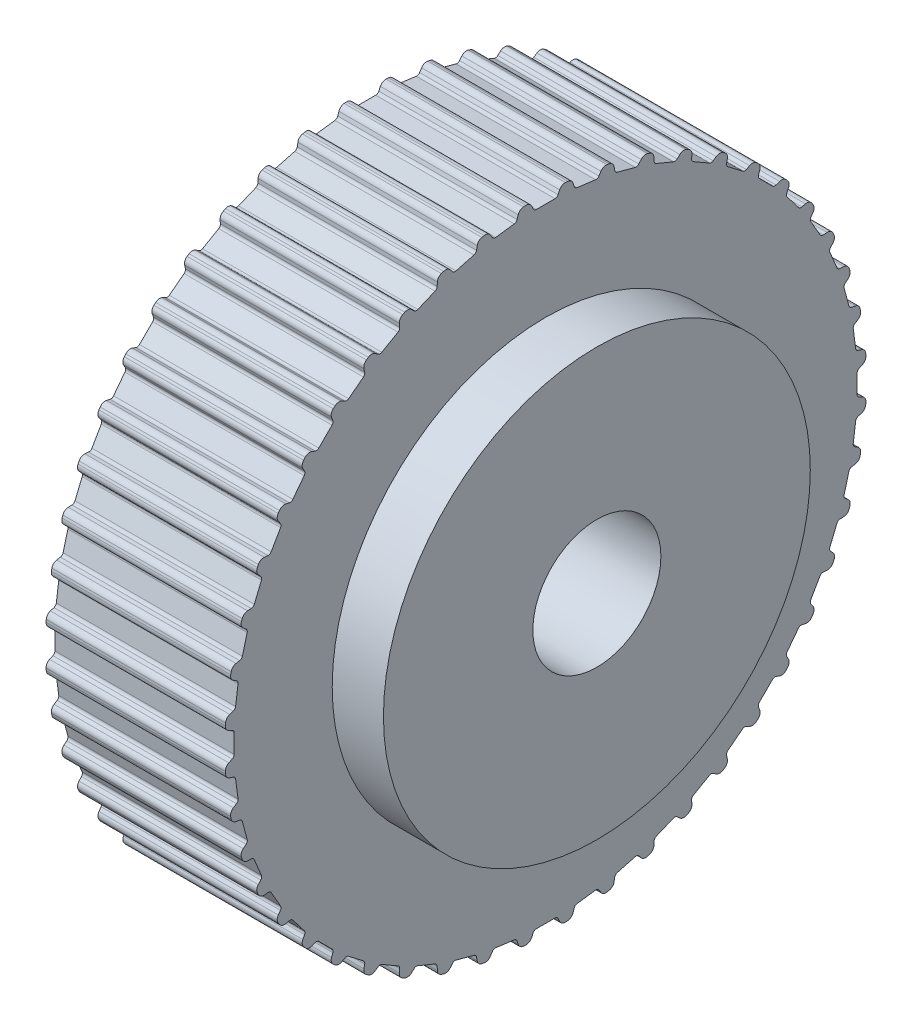
from build123d import *

# Parameters (mm, degrees)
SKETCH1_W                    = 21
SKETCH1_H                    = 37.585
CUT_EXTRUDE1_DEPTH           = 22
CUT_EXTRUDE2_DEPTH           = 22
CUT_EXTRUDE3_DEPTH           = 22
CUT_EXTRUDE4_DEPTH           = 22
CUT_EXTRUDE5_DEPTH           = 22
CUT_EXTRUDE6_DEPTH           = 22
CUT_EXTRUDE7_DEPTH           = 22
CUT_EXTRUDE8_DEPTH           = 22
CUT_EXTRUDE9_DEPTH           = 22
CUT_EXTRUDE10_DEPTH          = 22
CUT_EXTRUDE11_DEPTH          = 22
CUT_EXTRUDE12_DEPTH          = 22
CUT_EXTRUDE13_DEPTH          = 22
CUT_EXTRUDE14_DEPTH          = 22
CUT_EXTRUDE15_DEPTH          = 22
CUT_EXTRUDE16_DEPTH          = 22
CUT_EXTRUDE17_DEPTH          = 22
CUT_EXTRUDE18_DEPTH          = 22
CUT_EXTRUDE19_DEPTH          = 22
CUT_EXTRUDE20_DEPTH          = 22
CUT_EXTRUDE21_DEPTH          = 22
CUT_EXTRUDE22_DEPTH          = 22
CUT_EXTRUDE23_DEPTH          = 22
CUT_EXTRUDE24_DEPTH          = 22
CUT_EXTRUDE25_DEPTH          = 22
CUT_EXTRUDE26_DEPTH          = 22
CUT_EXTRUDE27_DEPTH          = 22
CUT_EXTRUDE28_DEPTH          = 22
CUT_EXTRUDE29_DEPTH          = 22
CUT_EXTRUDE30_DEPTH          = 22
CUT_EXTRUDE31_DEPTH          = 22
CUT_EXTRUDE32_DEPTH          = 22
CUT_EXTRUDE33_DEPTH          = 22
CUT_EXTRUDE34_DEPTH          = 22
CUT_EXTRUDE35_DEPTH          = 22
CUT_EXTRUDE36_DEPTH          = 22
CUT_EXTRUDE37_DEPTH          = 22
CUT_EXTRUDE38_DEPTH          = 22
CUT_EXTRUDE39_DEPTH          = 22
CUT_EXTRUDE40_DEPTH          = 22
CUT_EXTRUDE41_DEPTH          = 22
CUT_EXTRUDE42_DEPTH          = 22
CUT_EXTRUDE43_DEPTH          = 22
CUT_EXTRUDE44_DEPTH          = 22
CUT_EXTRUDE45_DEPTH          = 22
CUT_EXTRUDE46_DEPTH          = 22
CUT_EXTRUDE47_DEPTH          = 22
CUT_EXTRUDE48_DEPTH          = 22
SKETCH50_W                   = 6
SKETCH50_H                   = 25
F_8_0_8_DIAMETER_HOLE1_D     = 8
F_8_0_8_DIAMETER_HOLE1_DEPTH = 27
FILLET1_R                    = 0.4
FILLET2_R                    = 0.7
SKETCH53_R                   = 7.5
CUT_EXTRUDE49_DEPTH          = 28


with BuildPart() as part:
    # Sketch1 → Revolve1 (revolve)
    with BuildSketch(Plane(origin=(0, 0, 0), x_dir=(-1, 0, 0), z_dir=(0, 0, -1))):
        with Locations((-10.5, 18.7925)):
            Rectangle(SKETCH1_W, SKETCH1_H)
    revolve(axis=Axis((21, 0, 0), (-1, 0, 0)))

    # Sketch2 → Cut-Extrude1 (cut, through all)
    with BuildSketch(Plane.ZY):
        with BuildLine():
            Line((3.073809439, 37.459096633), (3.42379756, 36.349076127))
            Line((3.42379756, 36.349076127), (6.100698686, 35.996655408))
            Line((6.100698686, 35.996655408), (6.726055698, 36.978269291))
            ThreePointArc((6.726055698, 36.978269291), (4.905826935, 37.263455115), (3.073809439, 37.459096633))
        make_face()
    extrude(amount=-CUT_EXTRUDE1_DEPTH, mode=Mode.SUBTRACT)

    # Sketch3 → Cut-Extrude2 (cut, through all)
    with BuildSketch(Plane.ZY):
        with BuildLine():
            Line((7.936905821, 36.737416226), (8.139012995, 35.591209483))
            Line((8.139012995, 35.591209483), (10.747012726, 34.892398061))
            Line((10.747012726, 34.892398061), (11.495146045, 35.783988632))
            ThreePointArc((11.495146045, 35.783988632), (9.72771381, 36.304322181), (7.936905821, 36.737416226))
        make_face()
    extrude(amount=-CUT_EXTRUDE2_DEPTH, mode=Mode.SUBTRACT)

    # Sketch4 → Cut-Extrude3 (cut, through all)
    with BuildSketch(Plane.ZY):
        with BuildLine():
            Line((12.664199543, 35.387148443), (12.714967661, 34.224367377))
            Line((12.714967661, 34.224367377), (15.209442399, 33.19112211))
            Line((15.209442399, 33.19112211), (16.067551256, 33.977434006))
            ThreePointArc((16.067551256, 33.977434006), (14.383156805, 34.724012229), (12.664199543, 35.387148443))
        make_face()
    extrude(amount=-CUT_EXTRUDE3_DEPTH, mode=Mode.SUBTRACT)

    # Sketch5 → Cut-Extrude4 (cut, through all)
    with BuildSketch(Plane.ZY):
        with BuildLine():
            Line((17.1748053, 33.431396739), (17.073365705, 32.271936857))
            Line((17.073365705, 32.271936857), (19.411634295, 30.921936857))
            Line((19.411634295, 30.921936857), (20.365036209, 31.589516064))
            ThreePointArc((20.365036209, 31.589516064), (18.7925, 32.549564801), (17.1748053, 33.431396739))
        make_face()
    extrude(amount=-CUT_EXTRUDE4_DEPTH, mode=Mode.SUBTRACT)

    # Sketch6 → Cut-Extrude5 (cut, through all)
    with BuildSketch(Plane.ZY):
        with BuildLine():
            Line((21.391545377, 30.903624567), (21.139633728, 29.76732455))
            Line((21.139633728, 29.76732455), (23.281687747, 28.123668691))
            Line((23.281687747, 28.123668691), (24.314069748, 28.661092745))
            ThreePointArc((24.314069748, 28.661092745), (22.880298309, 29.818185295), (21.391545377, 30.903624567))
        make_face()
    extrude(amount=-CUT_EXTRUDE5_DEPTH, mode=Mode.SUBTRACT)

    # Sketch7 → Cut-Extrude6 (cut, through all)
    with BuildSketch(Plane.ZY):
        with BuildLine():
            Line((25.242270181, 27.847082811), (24.844196757, 26.753385066))
            Line((24.844196757, 26.753385066), (26.753385066, 24.844196757))
            Line((26.753385066, 24.844196757), (27.847082811, 25.242270181))
            ThreePointArc((27.847082811, 25.242270181), (26.576608371, 26.576608371), (25.242270181, 27.847082811))
        make_face()
    extrude(amount=-CUT_EXTRUDE6_DEPTH, mode=Mode.SUBTRACT)

    # Sketch8 → Cut-Extrude7 (cut, through all)
    with BuildSketch(Plane.ZY):
        with BuildLine():
            Line((28.661092745, 24.314069748), (28.123668691, 23.281687747))
            Line((28.123668691, 23.281687747), (29.76732455, 21.139633728))
            Line((29.76732455, 21.139633728), (30.903624567, 21.391545377))
            ThreePointArc((30.903624567, 21.391545377), (29.818185295, 22.880298309), (28.661092745, 24.314069748))
        make_face()
    extrude(amount=-CUT_EXTRUDE7_DEPTH, mode=Mode.SUBTRACT)

    # Sketch9 → Cut-Extrude8 (cut, through all)
    with BuildSketch(Plane.ZY):
        with BuildLine():
            Line((31.589516064, 20.365036209), (30.921936857, 19.411634295))
            Line((30.921936857, 19.411634295), (32.271936857, 17.073365705))
            Line((32.271936857, 17.073365705), (33.431396739, 17.1748053))
            ThreePointArc((33.431396739, 17.1748053), (32.549564801, 18.7925), (31.589516064, 20.365036209))
        make_face()
    extrude(amount=-CUT_EXTRUDE8_DEPTH, mode=Mode.SUBTRACT)

    # Sketch10 → Cut-Extrude9 (cut, through all)
    with BuildSketch(Plane.ZY):
        with BuildLine():
            Line((33.977434006, 16.067551256), (33.19112211, 15.209442399))
            Line((33.19112211, 15.209442399), (34.224367377, 12.714967661))
            Line((34.224367377, 12.714967661), (35.387148443, 12.664199543))
            ThreePointArc((35.387148443, 12.664199543), (34.724012229, 14.383156805), (33.977434006, 16.067551256))
        make_face()
    extrude(amount=-CUT_EXTRUDE9_DEPTH, mode=Mode.SUBTRACT)

    # Sketch11 → Cut-Extrude10 (cut, through all)
    with BuildSketch(Plane.ZY):
        with BuildLine():
            Line((35.783988632, 11.495146045), (34.892398061, 10.747012726))
            Line((34.892398061, 10.747012726), (35.591209483, 8.139012995))
            Line((35.591209483, 8.139012995), (36.737416226, 7.936905821))
            ThreePointArc((36.737416226, 7.936905821), (36.304322181, 9.72771381), (35.783988632, 11.495146045))
        make_face()
    extrude(amount=-CUT_EXTRUDE10_DEPTH, mode=Mode.SUBTRACT)

    # Sketch12 → Cut-Extrude11 (cut, through all)
    with BuildSketch(Plane.ZY):
        with BuildLine():
            Line((36.978269291, 6.726055698), (35.996655408, 6.100698686))
            Line((35.996655408, 6.100698686), (36.349076127, 3.42379756))
            Line((36.349076127, 3.42379756), (37.459096633, 3.073809439))
            ThreePointArc((37.459096633, 3.073809439), (37.263455115, 4.905826935), (36.978269291, 6.726055698))
        make_face()
    extrude(amount=-CUT_EXTRUDE11_DEPTH, mode=Mode.SUBTRACT)

    # Sketch13 → Cut-Extrude12 (cut, through all)
    with BuildSketch(Plane.ZY):
        with BuildLine():
            Line((37.53984151, 1.841880674), (36.485, 1.35))
            Line((36.485, 1.35), (36.485, -1.35))
            Line((36.485, -1.35), (37.53984151, -1.841880674))
            ThreePointArc((37.53984151, -1.841880674), (37.585, 0), (37.53984151, 1.841880674))
        make_face()
    extrude(amount=-CUT_EXTRUDE12_DEPTH, mode=Mode.SUBTRACT)

    # Sketch14 → Cut-Extrude13 (cut, through all)
    with BuildSketch(Plane.ZY):
        with BuildLine():
            Line((37.459096633, -3.073809439), (36.349076127, -3.42379756))
            Line((36.349076127, -3.42379756), (35.996655408, -6.100698686))
            Line((35.996655408, -6.100698686), (36.978269291, -6.726055698))
            ThreePointArc((36.978269291, -6.726055698), (37.263455115, -4.905826935), (37.459096633, -3.073809439))
        make_face()
    extrude(amount=-CUT_EXTRUDE13_DEPTH, mode=Mode.SUBTRACT)

    # Sketch15 → Cut-Extrude14 (cut, through all)
    with BuildSketch(Plane.ZY):
        with BuildLine():
            Line((36.737416226, -7.936905821), (35.591209483, -8.139012995))
            Line((35.591209483, -8.139012995), (34.892398061, -10.747012726))
            Line((34.892398061, -10.747012726), (35.783988632, -11.495146045))
            ThreePointArc((35.783988632, -11.495146045), (36.304322181, -9.72771381), (36.737416226, -7.936905821))
        make_face()
    extrude(amount=-CUT_EXTRUDE14_DEPTH, mode=Mode.SUBTRACT)

    # Sketch16 → Cut-Extrude15 (cut, through all)
    with BuildSketch(Plane.ZY):
        with BuildLine():
            Line((35.387148443, -12.664199543), (34.224367377, -12.714967661))
            Line((34.224367377, -12.714967661), (33.19112211, -15.209442399))
            Line((33.19112211, -15.209442399), (33.977434006, -16.067551256))
            ThreePointArc((33.977434006, -16.067551256), (34.724012229, -14.383156805), (35.387148443, -12.664199543))
        make_face()
    extrude(amount=-CUT_EXTRUDE15_DEPTH, mode=Mode.SUBTRACT)

    # Sketch17 → Cut-Extrude16 (cut, through all)
    with BuildSketch(Plane.ZY):
        with BuildLine():
            Line((33.431396739, -17.1748053), (32.271936857, -17.073365705))
            Line((32.271936857, -17.073365705), (30.921936857, -19.411634295))
            Line((30.921936857, -19.411634295), (31.589516064, -20.365036209))
            ThreePointArc((31.589516064, -20.365036209), (32.549564801, -18.7925), (33.431396739, -17.1748053))
        make_face()
    extrude(amount=-CUT_EXTRUDE16_DEPTH, mode=Mode.SUBTRACT)

    # Sketch18 → Cut-Extrude17 (cut, through all)
    with BuildSketch(Plane.ZY):
        with BuildLine():
            Line((30.903624567, -21.391545377), (29.76732455, -21.139633728))
            Line((29.76732455, -21.139633728), (28.123668691, -23.281687747))
            Line((28.123668691, -23.281687747), (28.661092745, -24.314069748))
            ThreePointArc((28.661092745, -24.314069748), (29.818185295, -22.880298309), (30.903624567, -21.391545377))
        make_face()
    extrude(amount=-CUT_EXTRUDE17_DEPTH, mode=Mode.SUBTRACT)

    # Sketch19 → Cut-Extrude18 (cut, through all)
    with BuildSketch(Plane.ZY):
        with BuildLine():
            Line((27.847082811, -25.242270181), (26.753385066, -24.844196757))
            Line((26.753385066, -24.844196757), (24.844196757, -26.753385066))
            Line((24.844196757, -26.753385066), (25.242270181, -27.847082811))
            ThreePointArc((25.242270181, -27.847082811), (26.576608371, -26.576608371), (27.847082811, -25.242270181))
        make_face()
    extrude(amount=-CUT_EXTRUDE18_DEPTH, mode=Mode.SUBTRACT)

    # Sketch20 → Cut-Extrude19 (cut, through all)
    with BuildSketch(Plane.ZY):
        with BuildLine():
            Line((24.314069748, -28.661092745), (23.281687747, -28.123668691))
            Line((23.281687747, -28.123668691), (21.139633728, -29.76732455))
            Line((21.139633728, -29.76732455), (21.391545377, -30.903624567))
            ThreePointArc((21.391545377, -30.903624567), (22.880298309, -29.818185295), (24.314069748, -28.661092745))
        make_face()
    extrude(amount=-CUT_EXTRUDE19_DEPTH, mode=Mode.SUBTRACT)

    # Sketch21 → Cut-Extrude20 (cut, through all)
    with BuildSketch(Plane.ZY):
        with BuildLine():
            Line((20.365036209, -31.589516064), (19.411634295, -30.921936857))
            Line((19.411634295, -30.921936857), (17.073365705, -32.271936857))
            Line((17.073365705, -32.271936857), (17.1748053, -33.431396739))
            ThreePointArc((17.1748053, -33.431396739), (18.7925, -32.549564801), (20.365036209, -31.589516064))
        make_face()
    extrude(amount=-CUT_EXTRUDE20_DEPTH, mode=Mode.SUBTRACT)

    # Sketch22 → Cut-Extrude21 (cut, through all)
    with BuildSketch(Plane.ZY):
        with BuildLine():
            Line((16.067551256, -33.977434006), (15.209442399, -33.19112211))
            Line((15.209442399, -33.19112211), (12.714967661, -34.224367377))
            Line((12.714967661, -34.224367377), (12.664199543, -35.387148443))
            ThreePointArc((12.664199543, -35.387148443), (14.383156805, -34.724012229), (16.067551256, -33.977434006))
        make_face()
    extrude(amount=-CUT_EXTRUDE21_DEPTH, mode=Mode.SUBTRACT)

    # Sketch23 → Cut-Extrude22 (cut, through all)
    with BuildSketch(Plane.ZY):
        with BuildLine():
            Line((11.495146045, -35.783988632), (10.747012726, -34.892398061))
            Line((10.747012726, -34.892398061), (8.139012995, -35.591209483))
            Line((8.139012995, -35.591209483), (7.936905821, -36.737416226))
            ThreePointArc((7.936905821, -36.737416226), (9.72771381, -36.304322181), (11.495146045, -35.783988632))
        make_face()
    extrude(amount=-CUT_EXTRUDE22_DEPTH, mode=Mode.SUBTRACT)

    # Sketch24 → Cut-Extrude23 (cut, through all)
    with BuildSketch(Plane.ZY):
        with BuildLine():
            Line((6.726055698, -36.978269291), (6.100698686, -35.996655408))
            Line((6.100698686, -35.996655408), (3.42379756, -36.349076127))
            Line((3.42379756, -36.349076127), (3.073809439, -37.459096633))
            ThreePointArc((3.073809439, -37.459096633), (4.905826935, -37.263455115), (6.726055698, -36.978269291))
        make_face()
    extrude(amount=-CUT_EXTRUDE23_DEPTH, mode=Mode.SUBTRACT)

    # Sketch25 → Cut-Extrude24 (cut, through all)
    with BuildSketch(Plane.ZY):
        with BuildLine():
            Line((1.841880674, -37.53984151), (1.35, -36.485))
            Line((1.35, -36.485), (-1.35, -36.485))
            Line((-1.35, -36.485), (-1.841880674, -37.53984151))
            ThreePointArc((-1.841880674, -37.53984151), (0, -37.585), (1.841880674, -37.53984151))
        make_face()
    extrude(amount=-CUT_EXTRUDE24_DEPTH, mode=Mode.SUBTRACT)

    # Sketch26 → Cut-Extrude25 (cut, through all)
    with BuildSketch(Plane.ZY):
        with BuildLine():
            Line((-3.073809439, -37.459096633), (-3.42379756, -36.349076127))
            Line((-3.42379756, -36.349076127), (-6.100698686, -35.996655408))
            Line((-6.100698686, -35.996655408), (-6.726055698, -36.978269291))
            ThreePointArc((-6.726055698, -36.978269291), (-4.905826935, -37.263455115), (-3.073809439, -37.459096633))
        make_face()
    extrude(amount=-CUT_EXTRUDE25_DEPTH, mode=Mode.SUBTRACT)

    # Sketch27 → Cut-Extrude26 (cut, through all)
    with BuildSketch(Plane.ZY):
        with BuildLine():
            Line((-7.936905821, -36.737416226), (-8.139012995, -35.591209483))
            Line((-8.139012995, -35.591209483), (-10.747012726, -34.892398061))
            Line((-10.747012726, -34.892398061), (-11.495146045, -35.783988632))
            ThreePointArc((-11.495146045, -35.783988632), (-9.72771381, -36.304322181), (-7.936905821, -36.737416226))
        make_face()
    extrude(amount=-CUT_EXTRUDE26_DEPTH, mode=Mode.SUBTRACT)

    # Sketch28 → Cut-Extrude27 (cut, through all)
    with BuildSketch(Plane.ZY):
        with BuildLine():
            Line((-12.664199543, -35.387148443), (-12.714967661, -34.224367377))
            Line((-12.714967661, -34.224367377), (-15.209442399, -33.19112211))
            Line((-15.209442399, -33.19112211), (-16.067551256, -33.977434006))
            ThreePointArc((-16.067551256, -33.977434006), (-14.383156805, -34.724012229), (-12.664199543, -35.387148443))
        make_face()
    extrude(amount=-CUT_EXTRUDE27_DEPTH, mode=Mode.SUBTRACT)

    # Sketch29 → Cut-Extrude28 (cut, through all)
    with BuildSketch(Plane.ZY):
        with BuildLine():
            Line((-17.1748053, -33.431396739), (-17.073365705, -32.271936857))
            Line((-17.073365705, -32.271936857), (-19.411634295, -30.921936857))
            Line((-19.411634295, -30.921936857), (-20.365036209, -31.589516064))
            ThreePointArc((-20.365036209, -31.589516064), (-18.7925, -32.549564801), (-17.1748053, -33.431396739))
        make_face()
    extrude(amount=-CUT_EXTRUDE28_DEPTH, mode=Mode.SUBTRACT)

    # Sketch30 → Cut-Extrude29 (cut, through all)
    with BuildSketch(Plane.ZY):
        with BuildLine():
            Line((-21.391545377, -30.903624567), (-21.139633728, -29.76732455))
            Line((-21.139633728, -29.76732455), (-23.281687747, -28.123668691))
            Line((-23.281687747, -28.123668691), (-24.314069748, -28.661092745))
            ThreePointArc((-24.314069748, -28.661092745), (-22.880298309, -29.818185295), (-21.391545377, -30.903624567))
        make_face()
    extrude(amount=-CUT_EXTRUDE29_DEPTH, mode=Mode.SUBTRACT)

    # Sketch31 → Cut-Extrude30 (cut, through all)
    with BuildSketch(Plane.ZY):
        with BuildLine():
            Line((-25.242270181, -27.847082811), (-24.844196757, -26.753385066))
            Line((-24.844196757, -26.753385066), (-26.753385066, -24.844196757))
            Line((-26.753385066, -24.844196757), (-27.847082811, -25.242270181))
            ThreePointArc((-27.847082811, -25.242270181), (-26.576608371, -26.576608371), (-25.242270181, -27.847082811))
        make_face()
    extrude(amount=-CUT_EXTRUDE30_DEPTH, mode=Mode.SUBTRACT)

    # Sketch32 → Cut-Extrude31 (cut, through all)
    with BuildSketch(Plane.ZY):
        with BuildLine():
            Line((-28.661092745, -24.314069748), (-28.123668691, -23.281687747))
            Line((-28.123668691, -23.281687747), (-29.76732455, -21.139633728))
            Line((-29.76732455, -21.139633728), (-30.903624567, -21.391545377))
            ThreePointArc((-30.903624567, -21.391545377), (-29.818185295, -22.880298309), (-28.661092745, -24.314069748))
        make_face()
    extrude(amount=-CUT_EXTRUDE31_DEPTH, mode=Mode.SUBTRACT)

    # Sketch33 → Cut-Extrude32 (cut, through all)
    with BuildSketch(Plane.ZY):
        with BuildLine():
            Line((-31.589516064, -20.365036209), (-30.921936857, -19.411634295))
            Line((-30.921936857, -19.411634295), (-32.271936857, -17.073365705))
            Line((-32.271936857, -17.073365705), (-33.431396739, -17.1748053))
            ThreePointArc((-33.431396739, -17.1748053), (-32.549564801, -18.7925), (-31.589516064, -20.365036209))
        make_face()
    extrude(amount=-CUT_EXTRUDE32_DEPTH, mode=Mode.SUBTRACT)

    # Sketch34 → Cut-Extrude33 (cut, through all)
    with BuildSketch(Plane.ZY):
        with BuildLine():
            Line((-33.977434006, -16.067551256), (-33.19112211, -15.209442399))
            Line((-33.19112211, -15.209442399), (-34.224367377, -12.714967661))
            Line((-34.224367377, -12.714967661), (-35.387148443, -12.664199543))
            ThreePointArc((-35.387148443, -12.664199543), (-34.724012229, -14.383156805), (-33.977434006, -16.067551256))
        make_face()
    extrude(amount=-CUT_EXTRUDE33_DEPTH, mode=Mode.SUBTRACT)

    # Sketch35 → Cut-Extrude34 (cut, through all)
    with BuildSketch(Plane.ZY):
        with BuildLine():
            Line((-35.783988632, -11.495146045), (-34.892398061, -10.747012726))
            Line((-34.892398061, -10.747012726), (-35.591209483, -8.139012995))
            Line((-35.591209483, -8.139012995), (-36.737416226, -7.936905821))
            ThreePointArc((-36.737416226, -7.936905821), (-36.304322181, -9.72771381), (-35.783988632, -11.495146045))
        make_face()
    extrude(amount=-CUT_EXTRUDE34_DEPTH, mode=Mode.SUBTRACT)

    # Sketch36 → Cut-Extrude35 (cut, through all)
    with BuildSketch(Plane.ZY):
        with BuildLine():
            Line((-36.978269291, -6.726055698), (-35.996655408, -6.100698686))
            Line((-35.996655408, -6.100698686), (-36.349076127, -3.42379756))
            Line((-36.349076127, -3.42379756), (-37.459096633, -3.073809439))
            ThreePointArc((-37.459096633, -3.073809439), (-37.263455115, -4.905826935), (-36.978269291, -6.726055698))
        make_face()
    extrude(amount=-CUT_EXTRUDE35_DEPTH, mode=Mode.SUBTRACT)

    # Sketch37 → Cut-Extrude36 (cut, through all)
    with BuildSketch(Plane.ZY):
        with BuildLine():
            Line((-37.53984151, -1.841880674), (-36.485, -1.35))
            Line((-36.485, -1.35), (-36.485, 1.35))
            Line((-36.485, 1.35), (-37.53984151, 1.841880674))
            ThreePointArc((-37.53984151, 1.841880674), (-37.585, 0), (-37.53984151, -1.841880674))
        make_face()
    extrude(amount=-CUT_EXTRUDE36_DEPTH, mode=Mode.SUBTRACT)

    # Sketch38 → Cut-Extrude37 (cut, through all)
    with BuildSketch(Plane.ZY):
        with BuildLine():
            Line((-37.459096633, 3.073809439), (-36.349076127, 3.42379756))
            Line((-36.349076127, 3.42379756), (-35.996655408, 6.100698686))
            Line((-35.996655408, 6.100698686), (-36.978269291, 6.726055698))
            ThreePointArc((-36.978269291, 6.726055698), (-37.263455115, 4.905826935), (-37.459096633, 3.073809439))
        make_face()
    extrude(amount=-CUT_EXTRUDE37_DEPTH, mode=Mode.SUBTRACT)

    # Sketch39 → Cut-Extrude38 (cut, through all)
    with BuildSketch(Plane.ZY):
        with BuildLine():
            Line((-36.737416226, 7.936905821), (-35.591209483, 8.139012995))
            Line((-35.591209483, 8.139012995), (-34.892398061, 10.747012726))
            Line((-34.892398061, 10.747012726), (-35.783988632, 11.495146045))
            ThreePointArc((-35.783988632, 11.495146045), (-36.304322181, 9.72771381), (-36.737416226, 7.936905821))
        make_face()
    extrude(amount=-CUT_EXTRUDE38_DEPTH, mode=Mode.SUBTRACT)

    # Sketch40 → Cut-Extrude39 (cut, through all)
    with BuildSketch(Plane.ZY):
        with BuildLine():
            Line((-35.387148443, 12.664199543), (-34.224367377, 12.714967661))
            Line((-34.224367377, 12.714967661), (-33.19112211, 15.209442399))
            Line((-33.19112211, 15.209442399), (-33.977434006, 16.067551256))
            ThreePointArc((-33.977434006, 16.067551256), (-34.724012229, 14.383156805), (-35.387148443, 12.664199543))
        make_face()
    extrude(amount=-CUT_EXTRUDE39_DEPTH, mode=Mode.SUBTRACT)

    # Sketch41 → Cut-Extrude40 (cut, through all)
    with BuildSketch(Plane.ZY):
        with BuildLine():
            Line((-33.431396739, 17.1748053), (-32.271936857, 17.073365705))
            Line((-32.271936857, 17.073365705), (-30.921936857, 19.411634295))
            Line((-30.921936857, 19.411634295), (-31.589516064, 20.365036209))
            ThreePointArc((-31.589516064, 20.365036209), (-32.549564801, 18.7925), (-33.431396739, 17.1748053))
        make_face()
    extrude(amount=-CUT_EXTRUDE40_DEPTH, mode=Mode.SUBTRACT)

    # Sketch42 → Cut-Extrude41 (cut, through all)
    with BuildSketch(Plane.ZY):
        with BuildLine():
            Line((-30.903624567, 21.391545377), (-29.76732455, 21.139633728))
            Line((-29.76732455, 21.139633728), (-28.123668691, 23.281687747))
            Line((-28.123668691, 23.281687747), (-28.661092745, 24.314069748))
            ThreePointArc((-28.661092745, 24.314069748), (-29.818185295, 22.880298309), (-30.903624567, 21.391545377))
        make_face()
    extrude(amount=-CUT_EXTRUDE41_DEPTH, mode=Mode.SUBTRACT)

    # Sketch43 → Cut-Extrude42 (cut, through all)
    with BuildSketch(Plane.ZY):
        with BuildLine():
            Line((-27.847082811, 25.242270181), (-26.753385066, 24.844196757))
            Line((-26.753385066, 24.844196757), (-24.844196757, 26.753385066))
            Line((-24.844196757, 26.753385066), (-25.242270181, 27.847082811))
            ThreePointArc((-25.242270181, 27.847082811), (-26.576608371, 26.576608371), (-27.847082811, 25.242270181))
        make_face()
    extrude(amount=-CUT_EXTRUDE42_DEPTH, mode=Mode.SUBTRACT)

    # Sketch44 → Cut-Extrude43 (cut, through all)
    with BuildSketch(Plane.ZY):
        with BuildLine():
            Line((-24.314069748, 28.661092745), (-23.281687747, 28.123668691))
            Line((-23.281687747, 28.123668691), (-21.139633728, 29.76732455))
            Line((-21.139633728, 29.76732455), (-21.391545377, 30.903624567))
            ThreePointArc((-21.391545377, 30.903624567), (-22.880298309, 29.818185295), (-24.314069748, 28.661092745))
        make_face()
    extrude(amount=-CUT_EXTRUDE43_DEPTH, mode=Mode.SUBTRACT)

    # Sketch45 → Cut-Extrude44 (cut, through all)
    with BuildSketch(Plane.ZY):
        with BuildLine():
            Line((-20.365036209, 31.589516064), (-19.411634295, 30.921936857))
            Line((-19.411634295, 30.921936857), (-17.073365705, 32.271936857))
            Line((-17.073365705, 32.271936857), (-17.1748053, 33.431396739))
            ThreePointArc((-17.1748053, 33.431396739), (-18.7925, 32.549564801), (-20.365036209, 31.589516064))
        make_face()
    extrude(amount=-CUT_EXTRUDE44_DEPTH, mode=Mode.SUBTRACT)

    # Sketch46 → Cut-Extrude45 (cut, through all)
    with BuildSketch(Plane.ZY):
        with BuildLine():
            Line((-16.067551256, 33.977434006), (-15.209442399, 33.19112211))
            Line((-15.209442399, 33.19112211), (-12.714967661, 34.224367377))
            Line((-12.714967661, 34.224367377), (-12.664199543, 35.387148443))
            ThreePointArc((-12.664199543, 35.387148443), (-14.383156805, 34.724012229), (-16.067551256, 33.977434006))
        make_face()
    extrude(amount=-CUT_EXTRUDE45_DEPTH, mode=Mode.SUBTRACT)

    # Sketch47 → Cut-Extrude46 (cut, through all)
    with BuildSketch(Plane.ZY):
        with BuildLine():
            Line((-11.495146045, 35.783988632), (-10.747012726, 34.892398061))
            Line((-10.747012726, 34.892398061), (-8.139012995, 35.591209483))
            Line((-8.139012995, 35.591209483), (-7.936905821, 36.737416226))
            ThreePointArc((-7.936905821, 36.737416226), (-9.72771381, 36.304322181), (-11.495146045, 35.783988632))
        make_face()
    extrude(amount=-CUT_EXTRUDE46_DEPTH, mode=Mode.SUBTRACT)

    # Sketch48 → Cut-Extrude47 (cut, through all)
    with BuildSketch(Plane.ZY):
        with BuildLine():
            Line((-6.726055698, 36.978269291), (-6.100698686, 35.996655408))
            Line((-6.100698686, 35.996655408), (-3.42379756, 36.349076127))
            Line((-3.42379756, 36.349076127), (-3.073809439, 37.459096633))
            ThreePointArc((-3.073809439, 37.459096633), (-4.905826935, 37.263455115), (-6.726055698, 36.978269291))
        make_face()
    extrude(amount=-CUT_EXTRUDE47_DEPTH, mode=Mode.SUBTRACT)

    # Sketch49 → Cut-Extrude48 (cut, through all)
    with BuildSketch(Plane.ZY):
        with BuildLine():
            Line((-1.841880674, 37.53984151), (-1.35, 36.485))
            Line((-1.35, 36.485), (1.35, 36.485))
            Line((1.35, 36.485), (1.841880674, 37.53984151))
            ThreePointArc((1.841880674, 37.53984151), (0, 37.585), (-1.841880674, 37.53984151))
        make_face()
    extrude(amount=-CUT_EXTRUDE48_DEPTH, mode=Mode.SUBTRACT)

    # Sketch50 → Revolve2 (revolve)
    with BuildSketch(Plane(origin=(0, 0, 0), x_dir=(-1, 0, 0), z_dir=(0, 0, -1))):
        with Locations((-24, 12.5)):
            Rectangle(SKETCH50_W, SKETCH50_H)
    revolve(axis=Axis((27, 0, 0), (-1, 0, 0)))

    # Ø8.0 (8) Diameter Hole1
    with Locations(Plane(origin=(27, 0, 0), x_dir=(0, 0, -1), z_dir=(1, 0, 0))):
        with Locations((0, 0)):
            Hole(F_8_0_8_DIAMETER_HOLE1_D / 2, depth=F_8_0_8_DIAMETER_HOLE1_DEPTH)

    # Fillet1
    fillet1_edges = [part.edges().sort_by_distance(p)[0] for p in [
        (10.5, 21.139633728, 29.76732455),
        (10.5, 23.281687747, 28.123668691),
        (10.5, 17.073365705, 32.271936857),
        (10.5, 19.411634295, 30.921936857),
        (10.5, 35.996655408, 6.100698686),
        (10.5, 12.714967661, 34.224367377),
        (10.5, 15.209442399, 33.19112211),
        (10.5, 36.349076127, 3.42379756),
        (10.5, 8.139012995, 35.591209483),
        (10.5, 10.747012726, 34.892398061),
        (10.5, 3.42379756, 36.349076127),
        (10.5, 6.100698686, 35.996655408),
        (10.5, -1.35, 36.485),
        (10.5, 1.35, 36.485),
        (10.5, -6.100698686, 35.996655408),
        (10.5, -3.42379756, 36.349076127),
        (10.5, -10.747012726, 34.892398061),
        (10.5, -8.139012995, 35.591209483),
        (10.5, -15.209442399, 33.19112211),
        (10.5, -12.714967661, 34.224367377),
        (10.5, -19.411634295, 30.921936857),
        (10.5, -17.073365705, 32.271936857),
        (10.5, -23.281687747, 28.123668691),
        (10.5, -21.139633728, 29.76732455),
        (10.5, 34.892398061, 10.747012726),
        (10.5, -26.753385066, 24.844196757),
        (10.5, -24.844196757, 26.753385066),
        (10.5, 35.591209483, 8.139012995),
        (10.5, -29.76732455, 21.139633728),
        (10.5, -28.123668691, 23.281687747),
        (10.5, -32.271936857, 17.073365705),
        (10.5, -30.921936857, 19.411634295),
        (10.5, -34.224367377, 12.714967661),
        (10.5, -33.19112211, 15.209442399),
        (10.5, -35.591209483, 8.139012995),
        (10.5, -34.892398061, 10.747012726),
        (10.5, -36.349076127, 3.42379756),
        (10.5, -35.996655408, 6.100698686),
        (10.5, -36.485, -1.35),
        (10.5, -36.485, 1.35),
        (10.5, -35.996655408, -6.100698686),
        (10.5, -36.349076127, -3.42379756),
        (10.5, -34.892398061, -10.747012726),
        (10.5, -35.591209483, -8.139012995),
        (10.5, -33.19112211, -15.209442399),
        (10.5, -34.224367377, -12.714967661),
        (10.5, -30.921936857, -19.411634295),
        (10.5, -32.271936857, -17.073365705),
        (10.5, 33.19112211, 15.209442399),
        (10.5, 34.224367377, 12.714967661),
        (10.5, -28.123668691, -23.281687747),
        (10.5, -29.76732455, -21.139633728),
        (10.5, -24.844196757, -26.753385066),
        (10.5, -26.753385066, -24.844196757),
        (10.5, -21.139633728, -29.76732455),
        (10.5, -23.281687747, -28.123668691),
        (10.5, -17.073365705, -32.271936857),
        (10.5, -19.411634295, -30.921936857),
        (10.5, -12.714967661, -34.224367377),
        (10.5, -15.209442399, -33.19112211),
        (10.5, -8.139012995, -35.591209483),
        (10.5, -10.747012726, -34.892398061),
        (10.5, -3.42379756, -36.349076127),
        (10.5, -6.100698686, -35.996655408),
        (10.5, 1.35, -36.485),
        (10.5, -1.35, -36.485),
        (10.5, 6.100698686, -35.996655408),
        (10.5, 3.42379756, -36.349076127),
        (10.5, 10.747012726, -34.892398061),
        (10.5, 8.139012995, -35.591209483),
        (10.5, 15.209442399, -33.19112211),
        (10.5, 12.714967661, -34.224367377),
        (10.5, 30.921936857, 19.411634295),
        (10.5, 32.271936857, 17.073365705),
        (10.5, 19.411634295, -30.921936857),
        (10.5, 17.073365705, -32.271936857),
        (10.5, 23.281687747, -28.123668691),
        (10.5, 21.139633728, -29.76732455),
        (10.5, 26.753385066, -24.844196757),
        (10.5, 24.844196757, -26.753385066),
        (10.5, 29.76732455, -21.139633728),
        (10.5, 28.123668691, -23.281687747),
        (10.5, 32.271936857, -17.073365705),
        (10.5, 30.921936857, -19.411634295),
        (10.5, 34.224367377, -12.714967661),
        (10.5, 33.19112211, -15.209442399),
        (10.5, 35.591209483, -8.139012995),
        (10.5, 34.892398061, -10.747012726),
        (10.5, 36.349076127, -3.42379756),
        (10.5, 35.996655408, -6.100698686),
        (10.5, 36.485, 1.35),
        (10.5, 36.485, -1.35),
        (10.5, 28.123668691, 23.281687747),
        (10.5, 29.76732455, 21.139633728),
        (10.5, 24.844196757, 26.753385066),
        (10.5, 26.753385066, 24.844196757),
    ]]
    fillet(fillet1_edges, radius=FILLET1_R)

    # Fillet2
    fillet2_edges = [part.edges().sort_by_distance(p)[0] for p in [
        (10.5, 24.314069748, 28.661092745),
        (10.5, 21.391545377, 30.903624567),
        (10.5, 20.365036209, 31.589516064),
        (10.5, 17.1748053, 33.431396739),
        (10.5, 37.459096633, 3.073809439),
        (10.5, 36.978269291, 6.726055698),
        (10.5, 16.067551256, 33.977434006),
        (10.5, 12.664199543, 35.387148443),
        (10.5, 11.495146045, 35.783988632),
        (10.5, 7.936905821, 36.737416226),
        (10.5, 6.726055698, 36.978269291),
        (10.5, 3.073809439, 37.459096633),
        (10.5, 1.841880674, 37.53984151),
        (10.5, -1.841880674, 37.53984151),
        (10.5, -3.073809439, 37.459096633),
        (10.5, -6.726055698, 36.978269291),
        (10.5, -7.936905821, 36.737416226),
        (10.5, -11.495146045, 35.783988632),
        (10.5, -12.664199543, 35.387148443),
        (10.5, -16.067551256, 33.977434006),
        (10.5, -17.1748053, 33.431396739),
        (10.5, -20.365036209, 31.589516064),
        (10.5, -21.391545377, 30.903624567),
        (10.5, -24.314069748, 28.661092745),
        (10.5, 36.737416226, 7.936905821),
        (10.5, 35.783988632, 11.495146045),
        (10.5, -25.242270181, 27.847082811),
        (10.5, -27.847082811, 25.242270181),
        (10.5, -28.661092745, 24.314069748),
        (10.5, -30.903624567, 21.391545377),
        (10.5, -31.589516064, 20.365036209),
        (10.5, -33.431396739, 17.1748053),
        (10.5, -33.977434006, 16.067551256),
        (10.5, -35.387148443, 12.664199543),
        (10.5, -35.783988632, 11.495146045),
        (10.5, -36.737416226, 7.936905821),
        (10.5, -36.978269291, 6.726055698),
        (10.5, -37.459096633, 3.073809439),
        (10.5, -37.53984151, 1.841880674),
        (10.5, -37.53984151, -1.841880674),
        (10.5, -37.459096633, -3.073809439),
        (10.5, -36.978269291, -6.726055698),
        (10.5, -36.737416226, -7.936905821),
        (10.5, -35.783988632, -11.495146045),
        (10.5, -35.387148443, -12.664199543),
        (10.5, -33.977434006, -16.067551256),
        (10.5, -33.431396739, -17.1748053),
        (10.5, 35.387148443, 12.664199543),
        (10.5, -31.589516064, -20.365036209),
        (10.5, 33.977434006, 16.067551256),
        (10.5, -30.903624567, -21.391545377),
        (10.5, -28.661092745, -24.314069748),
        (10.5, -27.847082811, -25.242270181),
        (10.5, -25.242270181, -27.847082811),
        (10.5, -24.314069748, -28.661092745),
        (10.5, -21.391545377, -30.903624567),
        (10.5, -20.365036209, -31.589516064),
        (10.5, -17.1748053, -33.431396739),
        (10.5, -16.067551256, -33.977434006),
        (10.5, -12.664199543, -35.387148443),
        (10.5, -11.495146045, -35.783988632),
        (10.5, -7.936905821, -36.737416226),
        (10.5, -6.726055698, -36.978269291),
        (10.5, -3.073809439, -37.459096633),
        (10.5, -1.841880674, -37.53984151),
        (10.5, 1.841880674, -37.53984151),
        (10.5, 3.073809439, -37.459096633),
        (10.5, 6.726055698, -36.978269291),
        (10.5, 7.936905821, -36.737416226),
        (10.5, 11.495146045, -35.783988632),
        (10.5, 33.431396739, 17.1748053),
        (10.5, 12.664199543, -35.387148443),
        (10.5, 16.067551256, -33.977434006),
        (10.5, 31.589516064, 20.365036209),
        (10.5, 17.1748053, -33.431396739),
        (10.5, 20.365036209, -31.589516064),
        (10.5, 21.391545377, -30.903624567),
        (10.5, 24.314069748, -28.661092745),
        (10.5, 25.242270181, -27.847082811),
        (10.5, 27.847082811, -25.242270181),
        (10.5, 28.661092745, -24.314069748),
        (10.5, 30.903624567, -21.391545377),
        (10.5, 31.589516064, -20.365036209),
        (10.5, 33.431396739, -17.1748053),
        (10.5, 33.977434006, -16.067551256),
        (10.5, 35.387148443, -12.664199543),
        (10.5, 35.783988632, -11.495146045),
        (10.5, 36.737416226, -7.936905821),
        (10.5, 36.978269291, -6.726055698),
        (10.5, 37.459096633, -3.073809439),
        (10.5, 37.53984151, -1.841880674),
        (10.5, 37.53984151, 1.841880674),
        (10.5, 30.903624567, 21.391545377),
        (10.5, 28.661092745, 24.314069748),
        (10.5, 27.847082811, 25.242270181),
        (10.5, 25.242270181, 27.847082811),
    ]]
    fillet(fillet2_edges, radius=FILLET2_R)

    # Sketch53 → Cut-Extrude49 (cut, through all)
    with BuildSketch(Plane(origin=(27, 0, 0), x_dir=(0, 0, -1), z_dir=(1, 0, 0))):
        Circle(SKETCH53_R)
    extrude(amount=-CUT_EXTRUDE49_DEPTH, mode=Mode.SUBTRACT)


solid = part.part
